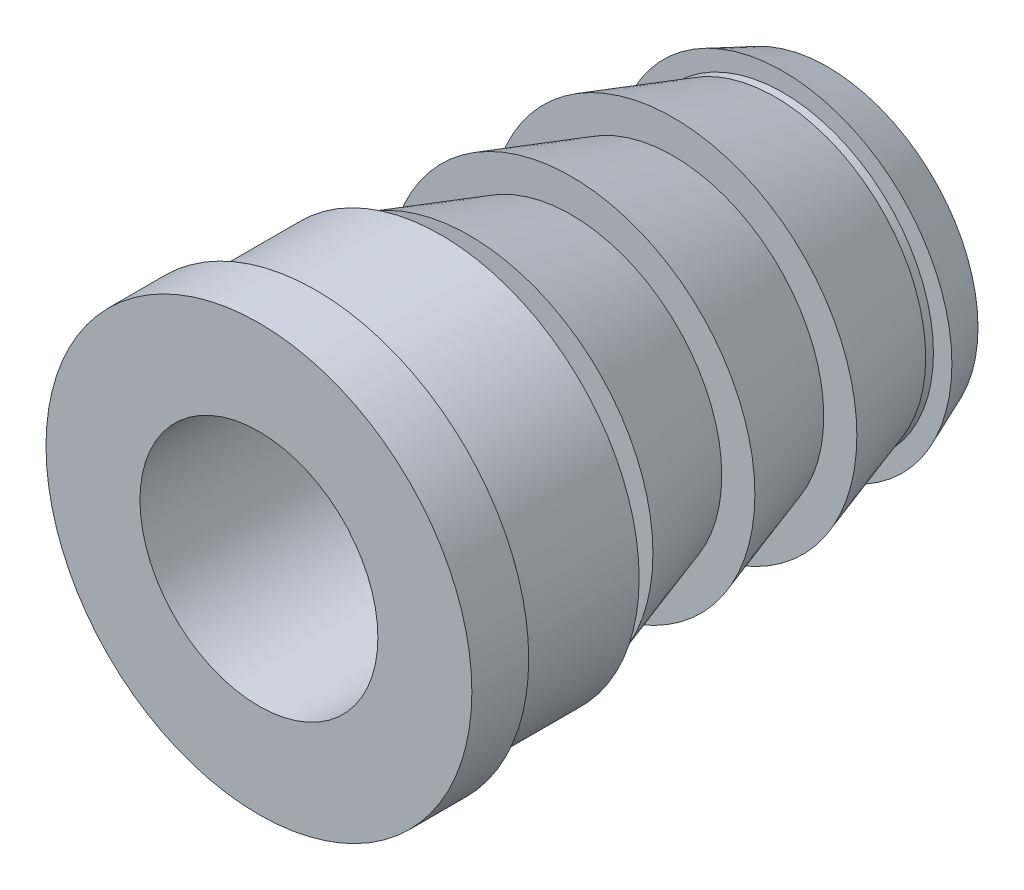
from build123d import *


with BuildPart() as part:
    # Sketch3 → Revolve1 (revolve)
    with BuildSketch(Plane(origin=(0, 0, 0), x_dir=(0, 0, -1), z_dir=(1, 0, 0))):
        Polygon((0.235837455, 1.2648), (0.235837455, 1.543333333), (1.093074909, 1.2648), (1.093074909, 1.543333333), (1.950312364, 1.2648), (2.015314055, 1.2648), (2.015314055, 1.42), (2.39, 1.2648), (2.39, 1), (-2.39, 1), (-2.39, 1.79), (-1.912, 1.79), (-1.912, 1.666666667), (-0.8604, 1.666666667), (-0.8604, 1.2648), (-0.6214, 1.2648), (-0.6214, 1.543333333), align=None)
    revolve(axis=Axis((0, 0, 2.39), (0, 0, -1)))


solid = part.part
